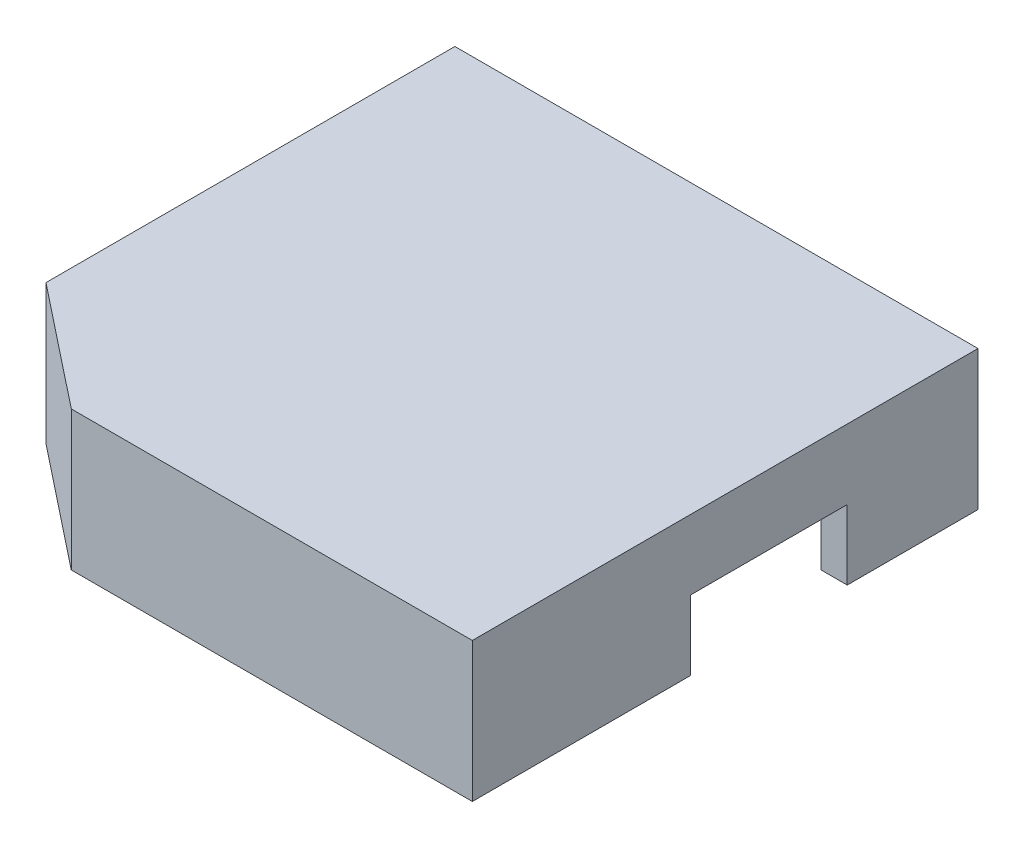
from build123d import *

# Parameters (mm, degrees)
SKETCH1_W           = 30
SKETCH1_H           = 29
BOSS_EXTRUDE1_DEPTH = 8
SKETCH2_W           = 24
SKETCH2_H           = 8
CUT_EXTRUDE1_DEPTH  = 8
CUT_EXTRUDE2_DEPTH  = 8
CUT_EXTRUDE3_DEPTH  = 5
SKETCH5_W           = 9
SKETCH5_H           = 4
CUT_EXTRUDE4_DEPTH  = 30
SKETCH2_2_W         = 24
SKETCH2_2_H         = 8
BOSS_EXTRUDE2_DEPTH = 3


with BuildPart() as part:
    # Sketch1 → Boss-Extrude1 (new body)
    with BuildSketch(Plane(origin=(0, 0, 0), x_dir=(1, 0, 0), z_dir=(0, 1, 0))):
        with Locations((-14.236607143, -13.569196429)):
            Rectangle(SKETCH1_W, SKETCH1_H)
    extrude(amount=BOSS_EXTRUDE1_DEPTH)

    # Sketch2 → Cut-Extrude1 (cut)
    with BuildSketch(Plane(origin=(0, 8, 0), x_dir=(1, 0, 0), z_dir=(0, 1, 0))):
        with Locations((-14.236607143, -6.069196429)):
            Rectangle(SKETCH2_W, SKETCH2_H)
        with Locations((-14.236607143, -17.069196429)):
            Rectangle(SKETCH2_W, SKETCH2_H)
    extrude(amount=-CUT_EXTRUDE1_DEPTH, mode=Mode.SUBTRACT)

    # Sketch3 → Cut-Extrude2 (cut)
    with BuildSketch(Plane(origin=(0, 8, 0), x_dir=(1, 0, 0), z_dir=(0, 1, 0))):
        Polygon((-29.236607143, -22.519140749), (-22.236607143, -28.069196429), (-29.236607143, -28.069196429), align=None)
    extrude(amount=-CUT_EXTRUDE2_DEPTH, mode=Mode.SUBTRACT)

    # Sketch4 → Cut-Extrude3 (cut)
    with BuildSketch(Plane.XZ):
        Polygon((-0.736607143, 0.569196429), (-27.736607143, 0.569196429), (-27.736607143, 21.794168589), (-21.714109927, 26.569196429), (-0.736607143, 26.569196429), align=None)
    extrude(amount=-CUT_EXTRUDE3_DEPTH, mode=Mode.SUBTRACT)

    # Sketch5 → Cut-Extrude4 (cut)
    with BuildSketch(Plane.ZY.offset(29.236607143)):
        with Locations((11.069196429, 2)):
            Rectangle(SKETCH5_W, SKETCH5_H)
    extrude(amount=-CUT_EXTRUDE4_DEPTH, mode=Mode.SUBTRACT)

    # Sketch2_2 → Boss-Extrude2 (add)
    with BuildSketch(Plane(origin=(0, 8, 0), x_dir=(1, 0, 0), z_dir=(0, 1, 0))):
        with Locations((-14.236607143, -6.069196429)):
            Rectangle(SKETCH2_2_W, SKETCH2_2_H)
        with Locations((-14.236607143, -17.069196429)):
            Rectangle(SKETCH2_2_W, SKETCH2_2_H)
    extrude(amount=-BOSS_EXTRUDE2_DEPTH)


solid = part.part
